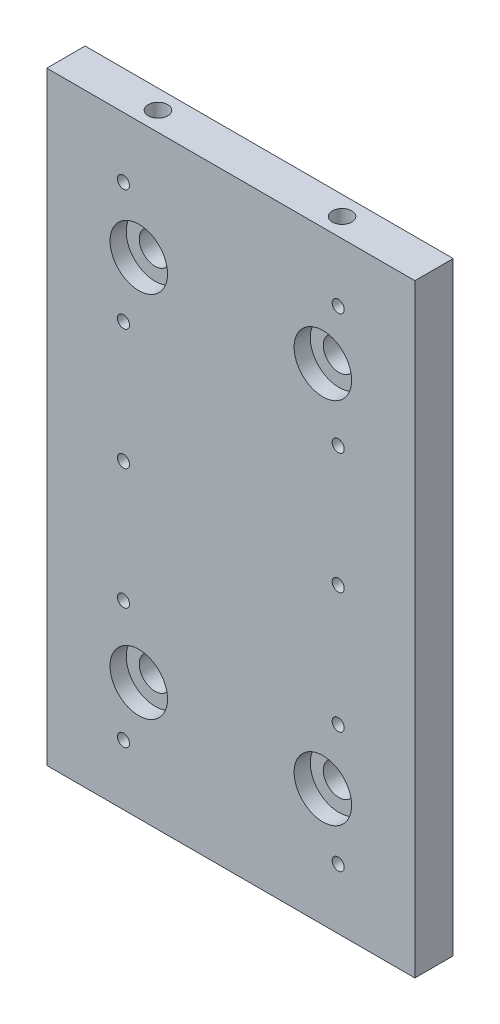
from build123d import *

# Parameters (mm, degrees)
SKETCH1_W                                        = 76.2
SKETCH1_H                                        = 125
BOSS_EXTRUDE1_DEPTH                              = 7.9375
CBORE_FOR_1_4_BUTTON_HEAD_CAP_SCREW1_D           = 6.5278
CBORE_FOR_1_4_BUTTON_HEAD_CAP_SCREW1_DEPTH       = 7.9375
CBORE_FOR_1_4_BUTTON_HEAD_CAP_SCREW1_CBORE_D     = 11.90752
CBORE_FOR_1_4_BUTTON_HEAD_CAP_SCREW1_CBORE_DEPTH = 3.3528
M3X0_5_TAPPED_HOLE1_D                            = 2.5
M3X0_5_TAPPED_HOLE1_DEPTH                        = 7.9375
F_10_32_TAPPED_HOLE1_D                           = 4.0386
F_10_32_TAPPED_HOLE1_DEPTH                       = 10.16
F_10_32_TAPPED_HOLE1_TIP                         = 1.213317848
F_10_32_TAPPED_HOLE2_D                           = 4.0386
F_10_32_TAPPED_HOLE2_DEPTH                       = 10.16
F_10_32_TAPPED_HOLE2_TIP                         = 1.213317848
CUT_EXTRUDE1_DEPTH                               = 4.7625


with BuildPart() as part:
    # Sketch1 → Boss-Extrude1 (new body)
    with BuildSketch(Plane.XY):
        Rectangle(SKETCH1_W, SKETCH1_H)
    extrude(amount=BOSS_EXTRUDE1_DEPTH)

    # CBORE for 1/4 Button Head Cap Screw1
    with Locations(Plane.XY.offset(7.9375)):
        with Locations((-19.05, 38.1), (19.05, 38.1), (19.05, -38.1), (-19.05, -38.1)):
            CounterBoreHole(CBORE_FOR_1_4_BUTTON_HEAD_CAP_SCREW1_D / 2, CBORE_FOR_1_4_BUTTON_HEAD_CAP_SCREW1_CBORE_D / 2, CBORE_FOR_1_4_BUTTON_HEAD_CAP_SCREW1_CBORE_DEPTH, depth=CBORE_FOR_1_4_BUTTON_HEAD_CAP_SCREW1_DEPTH)

    # M3x0.5 Tapped Hole1
    with Locations(Plane.XY.offset(7.9375)):
        with Locations((-22.225, 50), (-22.225, 25), (-22.225, 0), (-22.225, -25), (-22.225, -50), (22.225, -50), (22.225, -25), (22.225, 0), (22.225, 25), (22.225, 50)):
            Hole(M3X0_5_TAPPED_HOLE1_D / 2, depth=M3X0_5_TAPPED_HOLE1_DEPTH)

    # #10-32 Tapped Hole1
    with Locations(Plane(origin=(0, 62.5, 0), x_dir=(1, 0, 0), z_dir=(0, 1, 0))):
        with Locations((-19.05, -3.96875), (19.05, -3.96875)):
            Hole(F_10_32_TAPPED_HOLE1_D / 2, depth=F_10_32_TAPPED_HOLE1_DEPTH)
            with Locations((0, 0, -(F_10_32_TAPPED_HOLE1_DEPTH + F_10_32_TAPPED_HOLE1_TIP / 2))):  # 118° drill point
                Cone(0, F_10_32_TAPPED_HOLE1_D / 2, F_10_32_TAPPED_HOLE1_TIP, mode=Mode.SUBTRACT)

    # #10-32 Tapped Hole2
    with Locations(Plane(origin=(0, -62.5, 0), x_dir=(-1, 0, 0), z_dir=(0, -1, 0))):
        with Locations((19.05, -3.96875), (-19.05, -3.96875)):
            Hole(F_10_32_TAPPED_HOLE2_D / 2, depth=F_10_32_TAPPED_HOLE2_DEPTH)
            with Locations((0, 0, -(F_10_32_TAPPED_HOLE2_DEPTH + F_10_32_TAPPED_HOLE2_TIP / 2))):  # 118° drill point
                Cone(0, F_10_32_TAPPED_HOLE2_D / 2, F_10_32_TAPPED_HOLE2_TIP, mode=Mode.SUBTRACT)

    # Sketch10 → Cut-Extrude1 (cut)
    with BuildSketch(Plane(origin=(0, 0, 0), x_dir=(-1, 0, 0), z_dir=(0, 0, -1))):
        with BuildLine():
            Line((7.9375, -60.325), (-7.9375, -60.325))
            ThreePointArc((-7.9375, -60.325), (-11.305096045, -58.930096045), (-12.7, -55.5625))
            Line((-12.7, -55.5625), (-12.7, 55.5625))
            ThreePointArc((-12.7, 55.5625), (-11.305096045, 58.930096045), (-7.9375, 60.325))
            Line((-7.9375, 60.325), (7.9375, 60.325))
            ThreePointArc((7.9375, 60.325), (11.305096045, 58.930096045), (12.7, 55.5625))
            Line((12.7, 55.5625), (12.7, -55.5625))
            ThreePointArc((12.7, -55.5625), (11.305096045, -58.930096045), (7.9375, -60.325))
        make_face()
        with BuildLine():
            Line((-25.4, 55.5625), (-25.4, -55.5625))
            ThreePointArc((-25.4, -55.5625), (-30.1625, -60.325), (-34.925, -55.5625))
            Line((-34.925, -55.5625), (-34.925, 55.5625))
            ThreePointArc((-34.925, 55.5625), (-30.1625, 60.325), (-25.4, 55.5625))
        make_face()
        with BuildLine():
            Line((34.925, 55.5625), (34.925, -55.5625))
            ThreePointArc((34.925, -55.5625), (30.1625, -60.325), (25.4, -55.5625))
            Line((25.4, -55.5625), (25.4, 55.5625))
            ThreePointArc((25.4, 55.5625), (30.1625, 60.325), (34.925, 55.5625))
        make_face()
    extrude(amount=-CUT_EXTRUDE1_DEPTH, mode=Mode.SUBTRACT)


solid = part.part
